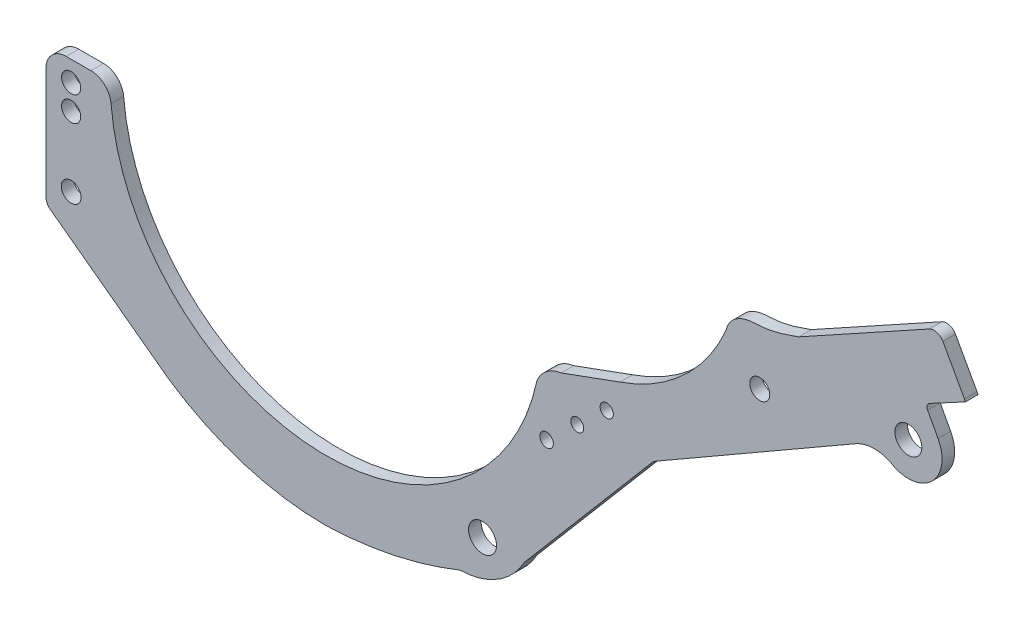
from build123d import *

# Parameters (mm, degrees)
ESBO_O1_R                = 27.71344859
ESBO_O1_R_2              = 19.642943244
ESBO_O1_R_3              = 19
ESBO_O1_R_4              = 13.503376128
ESBO_O1_R_5              = 12.848056377
ESBO_O1_R_6              = 13.183675058
ESBO_O1_R_7              = 19.84940304
ESBO_O1_R_8              = 26.715530758
RESSALTO_EXTRUS_O1_DEPTH = 25


with BuildPart() as part:
    # Esboço1 → Ressalto-extrusão1 (new body)
    with BuildSketch(Plane.XY):
        with BuildLine():
            Line((4413.114192809, 5114.37123775), (4411.288420867, 5118.493395975))
            Line((4411.288420867, 5118.493395975), (4368.528056031, 5195.933053436))
            ThreePointArc((4368.528056031, 5195.933053436), (4356.563983348, 5205.481641807), (4341.352234835, 5203.77363647))
            Line((4341.352234835, 5203.77363647), (4082.380260599, 5060.775378681))
            add(Edge.make_bspline(
                [(4082.380260599, 5060.775378681), (4060.653279964, 5053.050323004), (4026.458640538, 5040.417178177), (3971.383313993, 5041.975441307), (3943.204327614, 5021.389877069), (3939.014113572, 5001.580075286)],
                knots=[0, 0, 0, 0, 0.428929879, 0.656274084, 1, 1, 1, 1], degree=3))
            ThreePointArc((3939.014113572, 5001.580075286), (3854.618299216, 4881.369865741), (3728.462541381, 4806.151033491))
            Line((3728.462541381, 4806.151033491), (3611.066608375, 4763.191643283))
            ThreePointArc((3611.066608375, 4763.191643283), (3582.494949017, 4751.209944567), (3563.519721499, 4726.718281428))
            ThreePointArc((3563.519721499, 4726.718281428), (3118.29371103, 4388.982433408), (2718.593133711, 4779.534801123))
            ThreePointArc((2718.593133711, 4779.534801123), (2705.787983512, 4805.584059889), (2678.739524891, 4816.115756812))
            Line((2678.739524891, 4816.115756812), (2629.622746024, 4816.115756812))
            ThreePointArc((2629.622746024, 4816.115756812), (2601.338474777, 4804.400028059), (2589.622746024, 4776.115756812))
            Line((2589.622746024, 4776.115756812), (2589.622746024, 4553.908462806))
            ThreePointArc((2589.622746024, 4553.908462806), (2591.760392869, 4544.912000181), (2597.716380001, 4537.838663551))
            Line((2597.716380001, 4537.838663551), (2798.624846243, 4388.982433408))
            ThreePointArc((2798.624846243, 4388.982433408), (2961.516175194, 4298.989299254), (3144.993895299, 4267.872174271))
            add(Edge.make_bspline(
                [(3144.993895299, 4267.872174271), (3283.087901646, 4272.524252265), (3410.561847837, 4324.25862746)],
                knots=[0, 0, 0, 1, 1, 1], degree=2))
            ThreePointArc((3410.561847837, 4324.25862746), (3484.943379958, 4345.587286722), (3538.443267038, 4401.491545139))
            Line((3538.443267038, 4401.491545139), (3794.487917499, 4702.904338366))
            Line((3794.487917499, 4702.904338366), (4192.149360938, 4931.885643495))
            ThreePointArc((4192.149360938, 4931.885643495), (4227.105543109, 4943.536998483), (4263.361778436, 4936.966294947))
            ThreePointArc((4263.361778436, 4936.966294947), (4268.091109103, 4934.591237745), (4272.639430224, 4931.885643495))
            ThreePointArc((4272.639430224, 4931.885643495), (4348.822764296, 4947.270554666), (4358.86043695, 5024.340918684))
            Line((4358.86043695, 5024.340918684), (4338.204141009, 5062.928165106))
            ThreePointArc((4338.204141009, 5062.928165106), (4337.44919525, 5070.544509417), (4342.300936695, 5076.463905392))
            Line((4342.300936695, 5076.463905392), (4413.114192809, 5114.37123775))
        make_face()
        with Locations((3455.392827489, 4402.582392469)):
            Circle(ESBO_O1_R, mode=Mode.SUBTRACT)
        with Locations((2639.499035595, 4588.634415219)):
            Circle(ESBO_O1_R_2, mode=Mode.SUBTRACT)
        with Locations((2639.499035595, 4726.718281428)):
            Circle(ESBO_O1_R_3, mode=Mode.SUBTRACT)
        with Locations((3582.436878638, 4633.880010415)):
            Circle(ESBO_O1_R_4, mode=Mode.SUBTRACT)
        with Locations((3643.311799709, 4690.484232349)):
            Circle(ESBO_O1_R_5, mode=Mode.SUBTRACT)
        with Locations((2639.499035595, 4776.115756812)):
            Circle(ESBO_O1_R_3, mode=Mode.SUBTRACT)
        with Locations((3701.689462413, 4743.876157041)):
            Circle(ESBO_O1_R_6, mode=Mode.SUBTRACT)
        with Locations((4005.237906418, 4932.680988887)):
            Circle(ESBO_O1_R_7, mode=Mode.SUBTRACT)
        with Locations((4299.978946887, 4992.820828576)):
            Circle(ESBO_O1_R_8, mode=Mode.SUBTRACT)
    extrude(amount=RESSALTO_EXTRUS_O1_DEPTH)


solid = part.part
